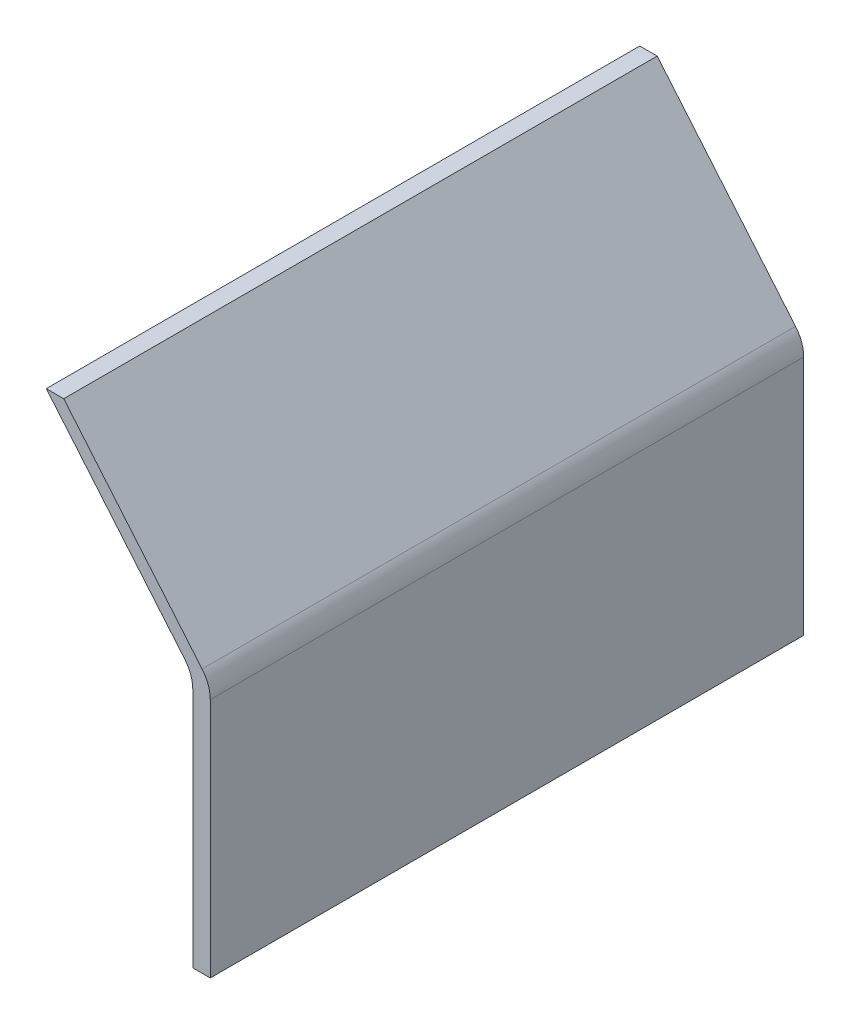
from build123d import *

# Parameters (mm, degrees)
FUNNEL_LEFT_SIDE_DEPTH = 170
FILLET1_R              = 10


with BuildPart() as part:
    # Sketch1 → Funnel - Left Side (new body)
    with BuildSketch(Plane.XY):
        Polygon((0, 0), (-5, 0), (-5, 72.7), (-46.974030913, 122.722702136), (-41.974030913, 122.722702136), (0, 72.7), align=None)
    extrude(amount=FUNNEL_LEFT_SIDE_DEPTH)

    # Fillet1
    fillet1_edges = [part.edges().sort_by_distance(p)[0] for p in [
        (-5, 72.7, 85),
        (0, 72.7, 85),
    ]]
    fillet(fillet1_edges, radius=FILLET1_R)


solid = part.part
